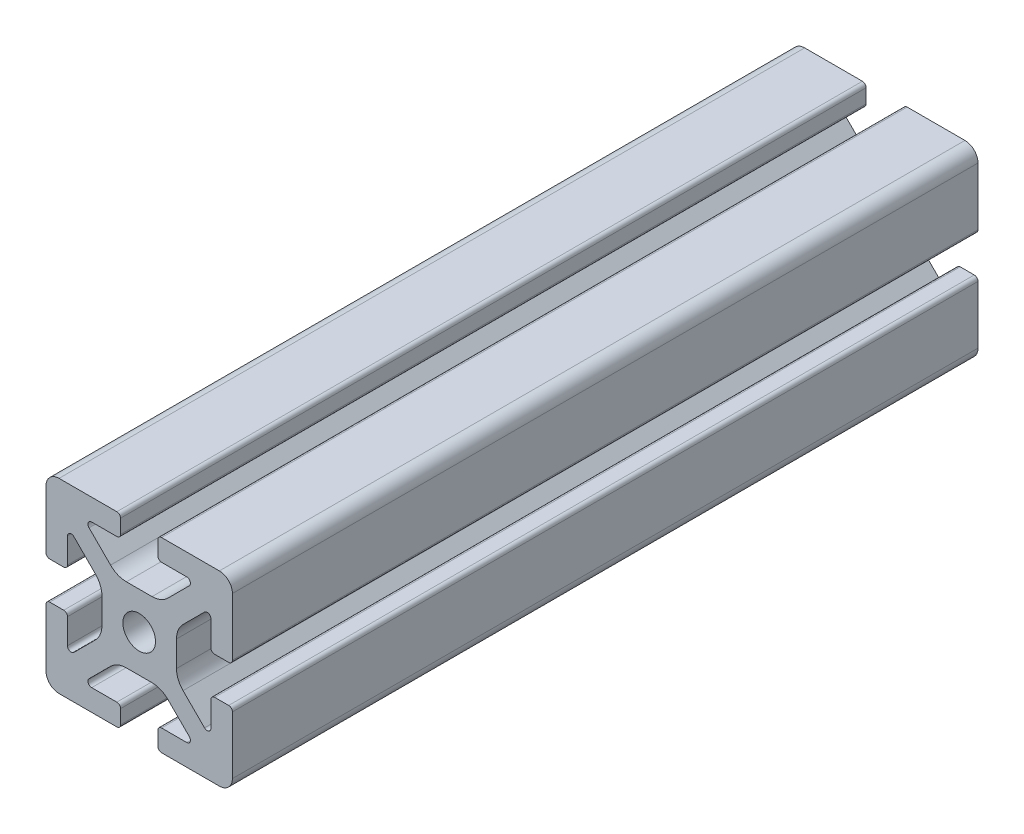
from build123d import *

# Parameters (mm, degrees)
BOSS_EXTRUDE1_DEPTH = 80


with BuildPart() as part:
    # Sketch4 → Boss-Extrude1 (new body, symmetric)
    with BuildSketch(Plane.XY):
        with BuildLine():
            Line((4.8, -20), (17.2, -20))
            ThreePointArc((17.2, -20), (19.179898987, -19.179898987), (20, -17.2))
            Line((20, -17.2), (20, -4.8))
            ThreePointArc((20, -4.8), (19.765685425, -4.234314575), (19.2, -4))
            Line((19.2, -4), (16.190663761, -4))
            ThreePointArc((16.190663761, -4), (15.624978336, -4.234314575), (15.390663761, -4.8))
            Line((15.390663761, -4.8), (15.390663761, -10.2))
            ThreePointArc((15.390663761, -10.2), (14.896810507, -10.939103626), (14.024978336, -10.765685425))
            Line((14.024978336, -10.765685425), (9.40588745, -6.146594539))
            ThreePointArc((9.40588745, -6.146594539), (8.365378244, -4.589362465), (8, -2.752481989))
            Line((8, -2.752481989), (8, 0))
            Line((8, 0), (3.5, 0))
            ThreePointArc((3.5, 0), (2.474873734, -2.474873734), (0, -3.5))
            Line((0, -3.5), (0, -8))
            Line((0, -8), (2.752481989, -8))
            ThreePointArc((2.752481989, -8), (4.589362465, -8.365378244), (6.146594539, -9.40588745))
            Line((6.146594539, -9.40588745), (10.765685425, -14.024978336))
            ThreePointArc((10.765685425, -14.024978336), (10.939103626, -14.896810507), (10.2, -15.390663761))
            Line((10.2, -15.390663761), (4.8, -15.390663761))
            ThreePointArc((4.8, -15.390663761), (4.234314575, -15.624978336), (4, -16.190663761))
            Line((4, -16.190663761), (4, -19.2))
            ThreePointArc((4, -19.2), (4.234314575, -19.765685425), (4.8, -20))
        make_face()
    extrude(amount=BOSS_EXTRUDE1_DEPTH, both=True)

    # Mirror1: part across plane


with BuildPart() as part_1:
    add(part.part)
    add(part.part.mirror(Plane(origin=(0, 0, 0), x_dir=(0, 0, 1), z_dir=(1, 0, 0))))

    # Mirror2: part across plane


with BuildPart() as part_2:
    add(part_1.part)
    add(part_1.part.mirror(Plane.ZX))


solid = part_2.part
